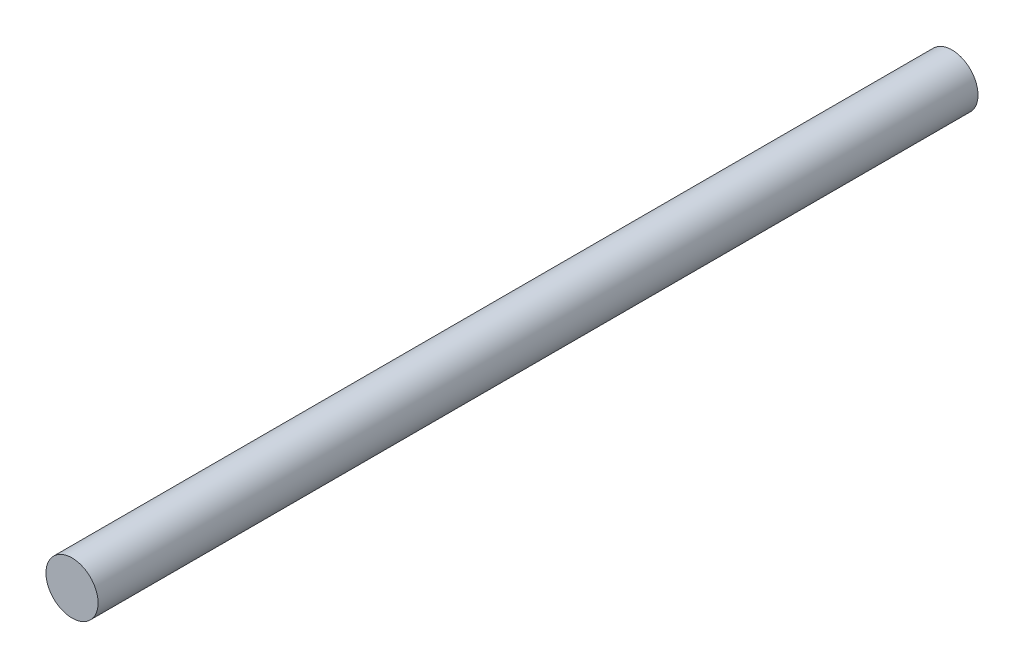
from build123d import *

# Parameters (mm, degrees)
SKETCH1_R           = 4
BOSS_EXTRUDE1_DEPTH = 135


with BuildPart() as part:
    # Sketch1 → Boss-Extrude1 (new body)
    with BuildSketch(Plane.XY):
        Circle(SKETCH1_R)
    extrude(amount=BOSS_EXTRUDE1_DEPTH)


solid = part.part
